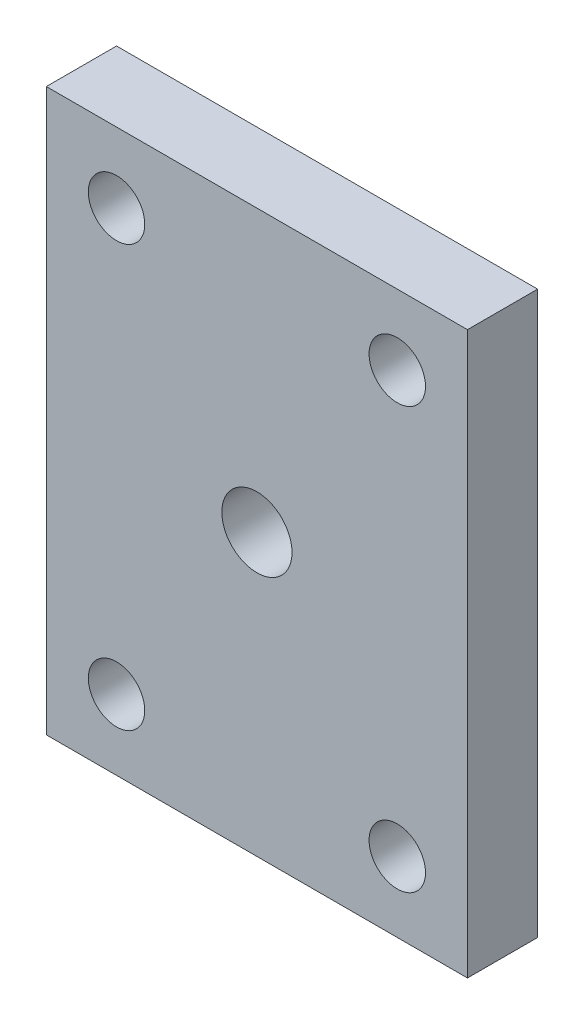
from build123d import *

# Parameters (mm, degrees)
SKETCH2_W           = 38.1
SKETCH2_H           = 50.8
SKETCH2_R           = 3.175
SKETCH2_R_2         = 2.5527
BOSS_EXTRUDE1_DEPTH = 6.35


with BuildPart() as part:
    # Sketch2 → Boss-Extrude1 (new body)
    with BuildSketch(Plane.XY):
        with Locations((19.05, 25.4)):
            Rectangle(SKETCH2_W, SKETCH2_H)
        with Locations((19.05, 25.4)):
            Circle(SKETCH2_R, mode=Mode.SUBTRACT)
        with Locations((6.35, 44.45)):
            Circle(SKETCH2_R_2, mode=Mode.SUBTRACT)
        with Locations((31.75, 44.45)):
            Circle(SKETCH2_R_2, mode=Mode.SUBTRACT)
        with Locations((31.75, 6.35)):
            Circle(SKETCH2_R_2, mode=Mode.SUBTRACT)
        with Locations((6.35, 6.35)):
            Circle(SKETCH2_R_2, mode=Mode.SUBTRACT)
    extrude(amount=BOSS_EXTRUDE1_DEPTH)


solid = part.part
